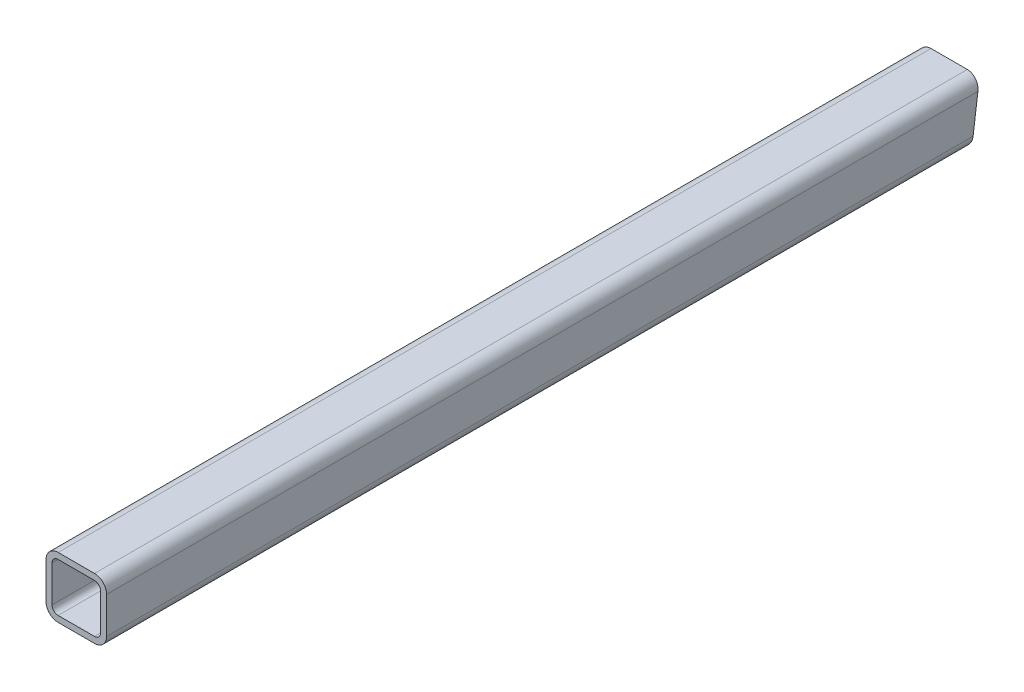
from build123d import *

# Parameters (mm, degrees)
BOSS_EXTRUDE1_DEPTH = 457.2
CUT_EXTRUDE1_DEPTH  = 914.4


with BuildPart() as part:
    # Sketch1 → Boss-Extrude1 (new body, symmetric)
    with BuildSketch(Plane.XY):
        with BuildLine():
            Line((19.05, 31.75), (-19.05, 31.75))
            ThreePointArc((-19.05, 31.75), (-28.030256121, 28.030256121), (-31.75, 19.05))
            Line((-31.75, 19.05), (-31.75, -19.05))
            ThreePointArc((-31.75, -19.05), (-28.030256121, -28.030256121), (-19.05, -31.75))
            Line((-19.05, -31.75), (19.05, -31.75))
            ThreePointArc((19.05, -31.75), (28.030256121, -28.030256121), (31.75, -19.05))
            Line((31.75, -19.05), (31.75, 19.05))
            ThreePointArc((31.75, 19.05), (28.030256121, 28.030256121), (19.05, 31.75))
        make_face()
        with BuildLine():
            ThreePointArc((-25.4, -19.05), (-23.540128061, -23.540128061), (-19.05, -25.4))
            Line((-19.05, -25.4), (19.05, -25.4))
            ThreePointArc((19.05, -25.4), (23.540128061, -23.540128061), (25.4, -19.05))
            Line((25.4, -19.05), (25.4, 19.05))
            ThreePointArc((25.4, 19.05), (23.540128061, 23.540128061), (19.05, 25.4))
            Line((19.05, 25.4), (-19.05, 25.4))
            ThreePointArc((-19.05, 25.4), (-23.540128061, 23.540128061), (-25.4, 19.05))
            Line((-25.4, 19.05), (-25.4, -19.05))
        make_face(mode=Mode.SUBTRACT)
    extrude(amount=BOSS_EXTRUDE1_DEPTH, both=True)

    # Sketch2 → Cut-Extrude1 (cut)
    with BuildSketch(Plane(origin=(31.75, 0, 0), x_dir=(0, 0, -1), z_dir=(1, 0, 0))):
        Polygon((457.2, 31.75), (457.2, -68.178184421), (444.044204942, -68.178184421), align=None)
    extrude(amount=-CUT_EXTRUDE1_DEPTH, mode=Mode.SUBTRACT)


solid = part.part
